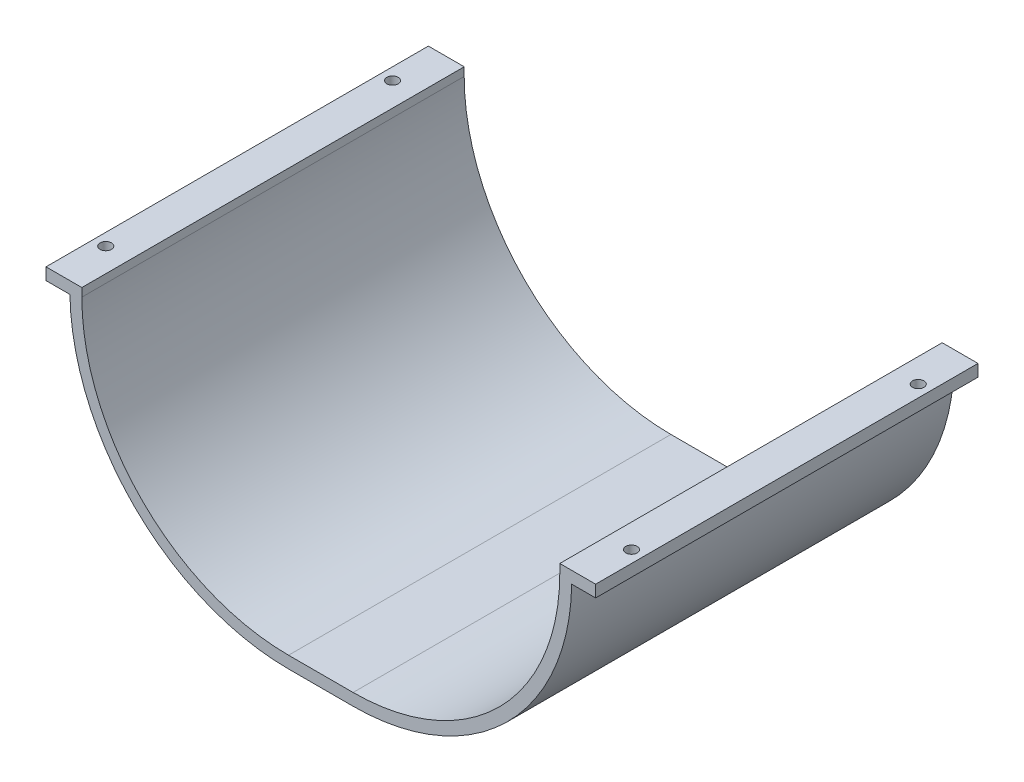
from build123d import *

# Parameters (mm, degrees)
BOSS_EXTRUDE1_DEPTH = 160
SKETCH2_R           = 2.38125
CUT_EXTRUDE1_DEPTH  = 160


with BuildPart() as part:
    # Sketch1 → Boss-Extrude1 (new body)
    with BuildSketch(Plane.XY):
        with BuildLine():
            Line((113.5, 0), (86.5, 0))
            ThreePointArc((86.5, 0), (25.335263427, 25.335263427), (0, 86.5))
            Line((0, 86.5), (0, 90))
            Line((0, 90), (-15, 90))
            Line((-15, 90), (-15, 85))
            Line((-15, 85), (-4.987704092, 85))
            ThreePointArc((-4.987704092, 85), (22.332251091, 21.271555285), (86.5, -5))
            Line((86.5, -5), (113.5, -5))
            ThreePointArc((113.5, -5), (177.667748909, 21.271555285), (204.987704092, 85))
            Line((204.987704092, 85), (215, 85))
            Line((215, 85), (215, 90))
            Line((215, 90), (200, 90))
            Line((200, 90), (200, 86.5))
            ThreePointArc((200, 86.5), (174.664736573, 25.335263427), (113.5, 0))
        make_face()
    extrude(amount=BOSS_EXTRUDE1_DEPTH)

    # Sketch2 → Cut-Extrude1 (cut)
    with BuildSketch(Plane.XZ.offset(-85)):
        with BuildLine():
            ThreePointArc((-9.993852046, 142.38125), (-12.375102046, 140), (-9.993852046, 137.61875))
            Line((-9.993852046, 137.61875), (-9.993852046, 142.38125))
        make_face()
        with BuildLine():
            Line((-9.993852046, 142.38125), (-9.993852046, 137.61875))
            ThreePointArc((-9.993852046, 137.61875), (-8.310054023, 138.316201977), (-7.612602046, 140))
            ThreePointArc((-7.612602046, 140), (-8.310054023, 141.683798023), (-9.993852046, 142.38125))
        make_face()
        with Locations((-9.993852046, 20)):
            Circle(SKETCH2_R)
        with Locations((209.993852046, 20)):
            Circle(SKETCH2_R)
        with Locations((209.993852046, 140)):
            Circle(SKETCH2_R)
    extrude(amount=-CUT_EXTRUDE1_DEPTH, mode=Mode.SUBTRACT)


solid = part.part
